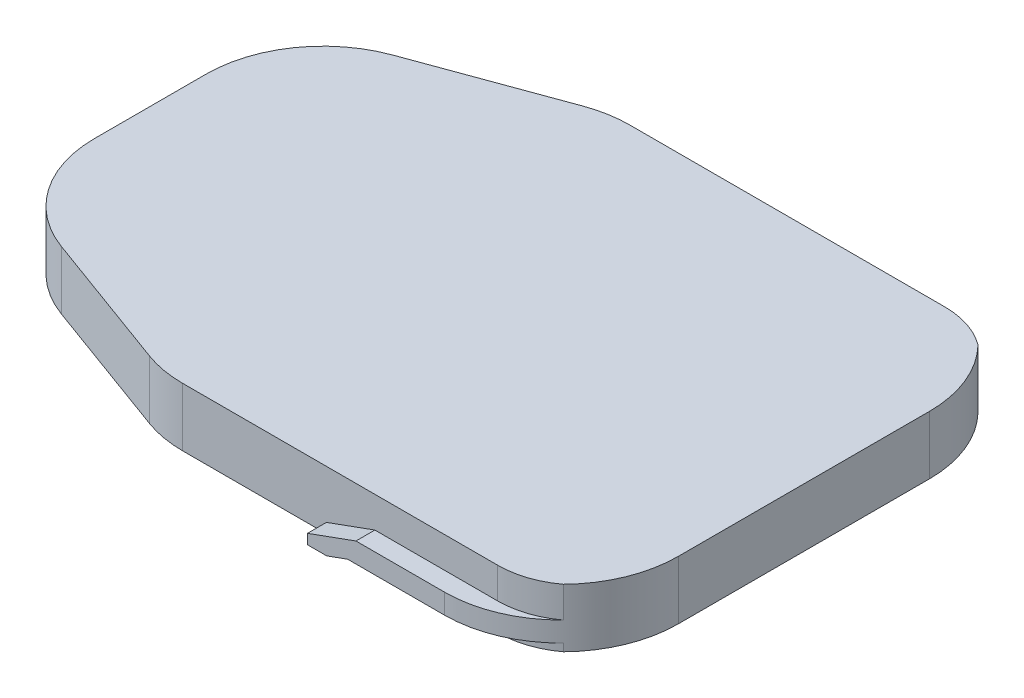
from build123d import *

# Parameters (mm, degrees)
EXTRUDE_1_DEPTH     = 8.5
CUT_EXTRUDE_1_DEPTH = 3.4
SKETCH_7_W          = 3.5
SKETCH_7_H          = 5.05
EXTRUDE_2_DEPTH     = 3.4
SKETCH_8_W          = 7.5
SKETCH_8_H          = 3.5
CUT_EXTRUDE_2_DEPTH = 3
EXTRUDE_3_DEPTH     = 2.75
FILLET_2_R          = 12
FILLET_3_R          = 17
FILLET_4_R          = 17


with BuildPart() as part:
    # 草图1 → 凸台-拉伸1 (new body)
    with BuildSketch(Plane(origin=(0, 0, 0), x_dir=(1, 0, 0), z_dir=(0, 1, 0))):
        Polygon((-47.5, 20), (-13.3, 32.5), (47.5, 32.5), (47.5, -32.5), (-13.3, -32.5), (-47.5, -20), align=None)
    extrude(amount=EXTRUDE_1_DEPTH)

    # 草图3 → 切除-拉伸1 (cut)
    with BuildSketch(Plane.XZ):
        with BuildLine():
            Line((-12.6, 29.55), (20.1, 29.55))
            ThreePointArc((20.1, 29.55), (34, 15.65), (20.1, 1.75))
            Line((20.1, 1.75), (-12.6, 1.75))
            ThreePointArc((-12.6, 1.75), (-26.5, 15.65), (-12.6, 29.55))
        make_face()
        with BuildLine():
            Line((-12.6, -29.55), (20.1, -29.55))
            ThreePointArc((20.1, -29.55), (34, -15.65), (20.1, -1.75))
            Line((20.1, -1.75), (-12.6, -1.75))
            ThreePointArc((-12.6, -1.75), (-26.5, -15.65), (-12.6, -29.55))
        make_face()
    extrude(amount=-CUT_EXTRUDE_1_DEPTH, mode=Mode.SUBTRACT)

    # 草图7 → 凸台-拉伸2 (add)
    with BuildSketch(Plane.XZ.offset(-3.4)):
        with Locations((3.75, 27.025)):
            Rectangle(SKETCH_7_W, SKETCH_7_H)
    extrude_2 = extrude(amount=EXTRUDE_2_DEPTH)

    # 镜向1: 凸台-拉伸2 across plane
    add(extrude_2.mirror(Plane.XY))

    # 草图8 → 切除-拉伸2 (cut)
    with BuildSketch(Plane.XZ):
        with Locations((3.75, 0)):
            Rectangle(SKETCH_8_W, SKETCH_8_H)
    extrude(amount=-CUT_EXTRUDE_2_DEPTH, mode=Mode.SUBTRACT)

    # 草图10 → 凸台-拉伸3 (add)
    with BuildSketch(Plane.XY.offset(32.5)):
        Polygon((16.429732781, 1.1), (47.5, 1.1), (47.5, 4), (17.642356602, 4), (10.6, 1.44163271), (10.6, 0), (13.401789026, 0), align=None)
    extrude_3 = extrude(amount=EXTRUDE_3_DEPTH)

    # 镜向2: 凸台-拉伸3 across plane
    add(extrude_3.mirror(Plane.XY))

    # 圆角2
    fillet_2_edges = [part.edges().sort_by_distance(p)[0] for p in [
        (47.5, 6.25, 32.5),
        (47.5, 0.55, -32.5),
        (47.5, 6.25, -32.5),
        (47.5, 0.55, 32.5),
    ]]
    fillet(fillet_2_edges, radius=FILLET_2_R)

    # 圆角3
    fillet_3_edges = [part.edges().sort_by_distance(p)[0] for p in [
        (47.5, 2.55, 35.25),
        (47.5, 2.55, -35.25),
    ]]
    fillet(fillet_3_edges, radius=FILLET_3_R)

    # 圆角4
    fillet_4_edges = [part.edges().sort_by_distance(p)[0] for p in [
        (-13.3, 4.25, 32.5),
        (-47.5, 4.25, 20),
        (-47.5, 4.25, -20),
        (-13.3, 4.25, -32.5),
    ]]
    fillet(fillet_4_edges, radius=FILLET_4_R)


solid = part.part
